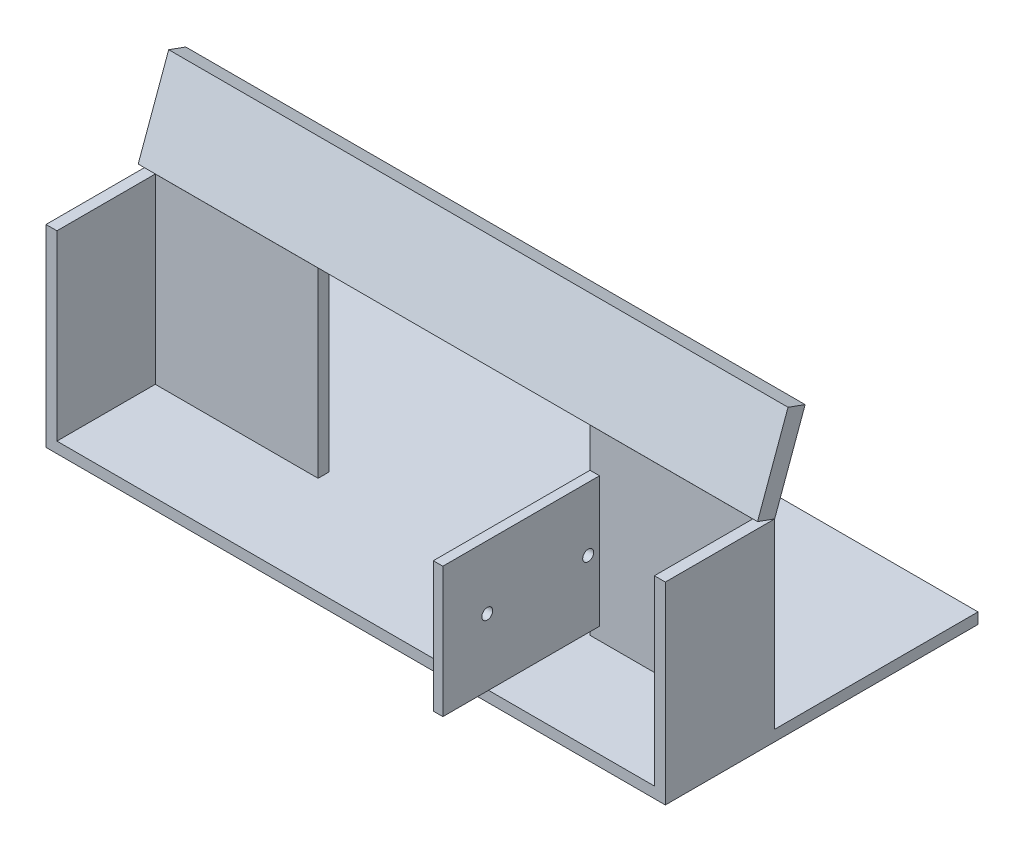
from build123d import *

# Parameters (mm, degrees)
SKETCH_1_W          = 170
SKETCH_1_H          = 30
SKETCH_1_W_2        = 164
SKETCH_1_H_2        = 24
EXTRUDE_1_DEPTH     = 50
SKETCH_2_W          = 170
SKETCH_2_H          = 4.475871816
EXTRUDE_2_DEPTH     = 5
SKETCH_4_W          = 170
SKETCH_4_H          = 5
EXTRUDE_4_DEPTH     = 20
SKETCH_5_W          = 164
SKETCH_5_H          = 3
CUT_EXTRUDE_1_DEPTH = 51
SKETCH_6_W          = 170
SKETCH_6_H          = 85.817423509
EXTRUDE_5_DEPTH     = 3
SKETCH_7_W          = 74.63245353
SKETCH_7_H          = 50
CUT_EXTRUDE_2_DEPTH = 59.817423509
SKETCH_8_W          = 2.615260917
SKETCH_8_H          = 35.768956176
EXTRUDE_6_DEPTH     = 43
SKETCH_10_R         = 1.5
CUT_EXTRUDE_3_DEPTH = 13


with BuildPart() as part:
    # 草图1 → 凸台-拉伸1 (new body)
    with BuildSketch(Plane(origin=(0, 0, 0), x_dir=(1, 0, 0), z_dir=(0, 1, 0))):
        Rectangle(SKETCH_1_W, SKETCH_1_H)
        Rectangle(SKETCH_1_W_2, SKETCH_1_H_2, mode=Mode.SUBTRACT)
    extrude(amount=EXTRUDE_1_DEPTH)

    # 草图5 → 切除-拉伸1 (cut, through all)
    with BuildSketch(Plane(origin=(0, 50, 0), x_dir=(1, 0, 0), z_dir=(0, 1, 0))):
        with Locations((0, -13.5)):
            Rectangle(SKETCH_5_W, SKETCH_5_H)
    extrude(amount=-CUT_EXTRUDE_1_DEPTH, mode=Mode.SUBTRACT)

    # 草图6 → 凸台-拉伸5 (add)
    with BuildSketch(Plane.XZ):
        with Locations((0, -27.908711755)):
            Rectangle(SKETCH_6_W, SKETCH_6_H)
    extrude(amount=EXTRUDE_5_DEPTH)

    # 草图7 → 切除-拉伸2 (cut, through all)
    with BuildSketch(Plane.XY.offset(-12)):
        with Locations((0, 25)):
            Rectangle(SKETCH_7_W, SKETCH_7_H)
    extrude(amount=-CUT_EXTRUDE_2_DEPTH, mode=Mode.SUBTRACT)

    # 草图8 → 凸台-拉伸6 (add)
    with BuildSketch(Plane.XY.offset(-12)):
        with Locations((38.623857224, 21.345785944)):
            Rectangle(SKETCH_8_W, SKETCH_8_H)
    extrude(amount=EXTRUDE_6_DEPTH)

    # 草图10 → 切除-拉伸3 (cut)
    with BuildSketch(Plane(origin=(39.931487682, 0, 0), x_dir=(0, 0, -1), z_dir=(1, 0, 0))):
        with Locations((-18.815259496, 21.83659903)):
            Circle(SKETCH_10_R)
        with Locations((8.884740504, 21.83659903)):
            Circle(SKETCH_10_R)
    extrude(amount=-CUT_EXTRUDE_3_DEPTH, mode=Mode.SUBTRACT)


with BuildPart() as body_2:
    # 草图2 → 凸台-拉伸2 (new body)
    with BuildSketch(Plane(origin=(0, 1.027981849, 2.824356919), x_dir=(-1, 0, 0), z_dir=(0, 0.342020143, 0.939692621))):
        with Locations((0, -54.352869097)):
            Rectangle(SKETCH_2_W, SKETCH_2_H)
    extrude(amount=EXTRUDE_2_DEPTH)

    # 草图4 → 凸台-拉伸4 (add)
    with BuildSketch(Plane(origin=(0, 53.177961867, -19.355195239), x_dir=(1, 0, 0), z_dir=(0, 0.939692621, -0.342020143))):
        with Locations((0, -5.505617854)):
            Rectangle(SKETCH_4_W, SKETCH_4_H)
    extrude(amount=EXTRUDE_4_DEPTH)


solid = Compound([part.part, body_2.part])
